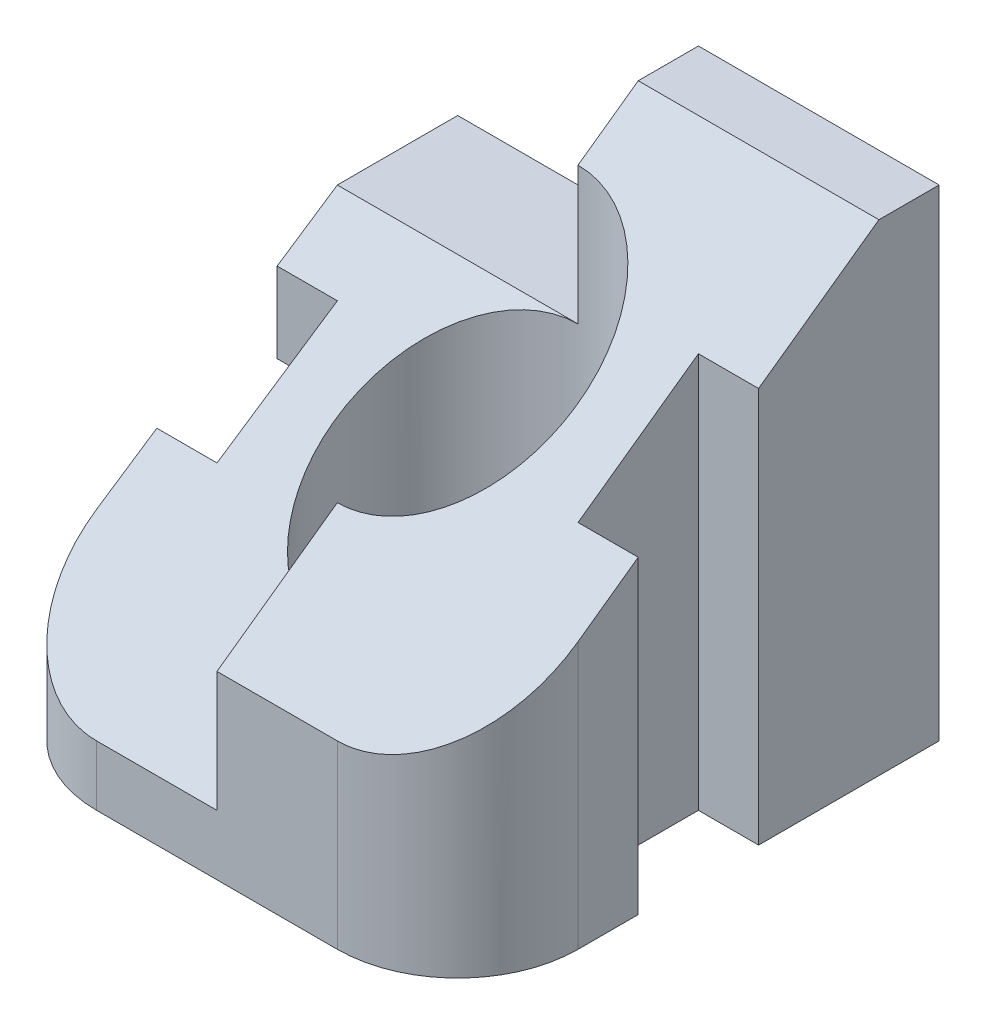
from build123d import *

# Parameters (mm, degrees)
SKETCH1_W           = 40
SKETCH1_H           = 40
BOSS_EXTRUDE1_DEPTH = 40
SKETCH2_R           = 10
CUT_EXTRUDE1_DEPTH  = 41
SKETCH3_W           = 5
SKETCH3_H           = 10
CUT_EXTRUDE2_DEPTH  = 41
CUT_EXTRUDE5_DEPTH  = 41
CUT_EXTRUDE6_DEPTH  = 41
SKETCH8_W           = 15
SKETCH8_H           = 15
CUT_EXTRUDE7_DEPTH  = 5
SKETCH9_W           = 15
SKETCH9_H           = 15
CUT_EXTRUDE8_DEPTH  = 20
CUT_EXTRUDE9_DEPTH  = 20
CUT_EXTRUDE10_DEPTH = 20


with BuildPart() as part:
    # Sketch1 → Boss-Extrude1 (new body)
    with BuildSketch(Plane.XY):
        Rectangle(SKETCH1_W, SKETCH1_H)
    extrude(amount=BOSS_EXTRUDE1_DEPTH)

    # Sketch2 → Cut-Extrude1 (cut, through all)
    with BuildSketch(Plane(origin=(0, 20, 0), x_dir=(1, 0, 0), z_dir=(0, 1, 0))):
        with Locations((0, -20)):
            Circle(SKETCH2_R)
    extrude(amount=-CUT_EXTRUDE1_DEPTH, mode=Mode.SUBTRACT)

    # Sketch3 → Cut-Extrude2 (cut, through all)
    with BuildSketch(Plane(origin=(0, 20, 0), x_dir=(1, 0, 0), z_dir=(0, 1, 0))):
        with Locations((17.5, -20)):
            Rectangle(SKETCH3_W, SKETCH3_H)
        with Locations((-17.5, -20)):
            Rectangle(SKETCH3_W, SKETCH3_H)
    extrude(amount=-CUT_EXTRUDE2_DEPTH, mode=Mode.SUBTRACT)

    # Sketch5 → Cut-Extrude5 (cut, through all)
    with BuildSketch(Plane(origin=(0, 20, 0), x_dir=(1, 0, 0), z_dir=(0, 1, 0))):
        with BuildLine():
            Line((-10, -40), (-20, -40))
            Line((-20, -40), (-20, -30))
            ThreePointArc((-20, -30), (-17.071067812, -37.071067812), (-10, -40))
        make_face()
    extrude(amount=-CUT_EXTRUDE5_DEPTH, mode=Mode.SUBTRACT)

    # Sketch7 → Cut-Extrude6 (cut, through all)
    with BuildSketch(Plane(origin=(0, 20, 0), x_dir=(1, 0, 0), z_dir=(0, 1, 0))):
        with BuildLine():
            Line((20, -30), (20, -40))
            Line((20, -40), (10, -40))
            ThreePointArc((10, -40), (17.071067812, -37.071067812), (20, -30))
        make_face()
    extrude(amount=-CUT_EXTRUDE6_DEPTH, mode=Mode.SUBTRACT)

    # Sketch8 → Cut-Extrude7 (cut)
    with BuildSketch(Plane.ZY.offset(20)):
        with Locations((7.5, -12.5)):
            Rectangle(SKETCH8_W, SKETCH8_H)
    extrude(amount=-CUT_EXTRUDE7_DEPTH, mode=Mode.SUBTRACT)

    # Sketch9 → Cut-Extrude8 (cut)
    with BuildSketch(Plane.ZY.offset(20)):
        with Locations((7.5, 12.5)):
            Rectangle(SKETCH9_W, SKETCH9_H)
    extrude(amount=-CUT_EXTRUDE8_DEPTH, mode=Mode.SUBTRACT)

    # Sketch10 → Cut-Extrude9 (cut)
    with BuildSketch(Plane(origin=(-20, 0, 0), x_dir=(0, 0, -1), z_dir=(1, 0, 0))):
        Polygon((-10, 5), (-40, -15), (-40, 20), (-10, 20), align=None)
    extrude(amount=CUT_EXTRUDE9_DEPTH, mode=Mode.SUBTRACT)

    # Sketch11 → Cut-Extrude10 (cut)
    with BuildSketch(Plane(origin=(20, 0, 0), x_dir=(0, 0, -1), z_dir=(1, 0, 0))):
        Polygon((-5, 20), (-40, -5), (-40, 20), align=None)
    extrude(amount=-CUT_EXTRUDE10_DEPTH, mode=Mode.SUBTRACT)


solid = part.part
